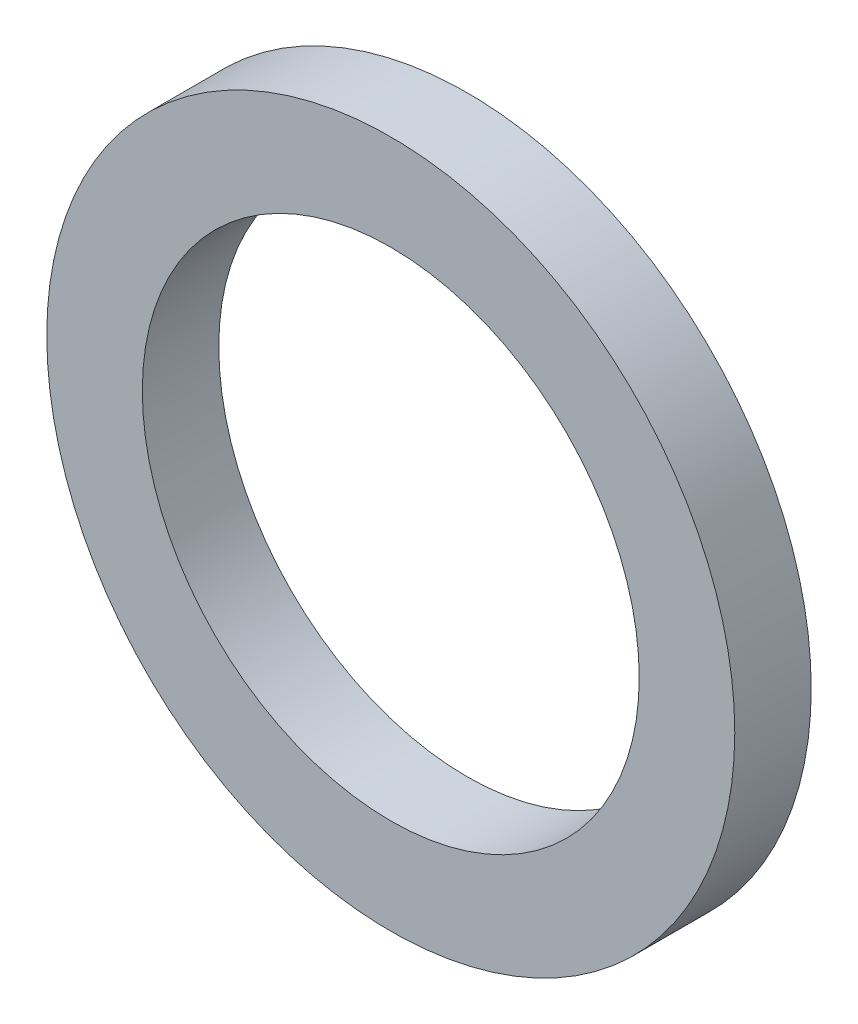
from build123d import *

# Parameters (mm, degrees)
SKETCH_1_R      = 5.4
SKETCH_1_R_2    = 3.9
EXTRUDE_1_DEPTH = 1.2


with BuildPart() as part:
    # 草图1 → 凸台-拉伸1 (new body)
    with BuildSketch(Plane.XY):
        Circle(SKETCH_1_R)
        Circle(SKETCH_1_R_2, mode=Mode.SUBTRACT)
    extrude(amount=EXTRUDE_1_DEPTH)


solid = part.part
